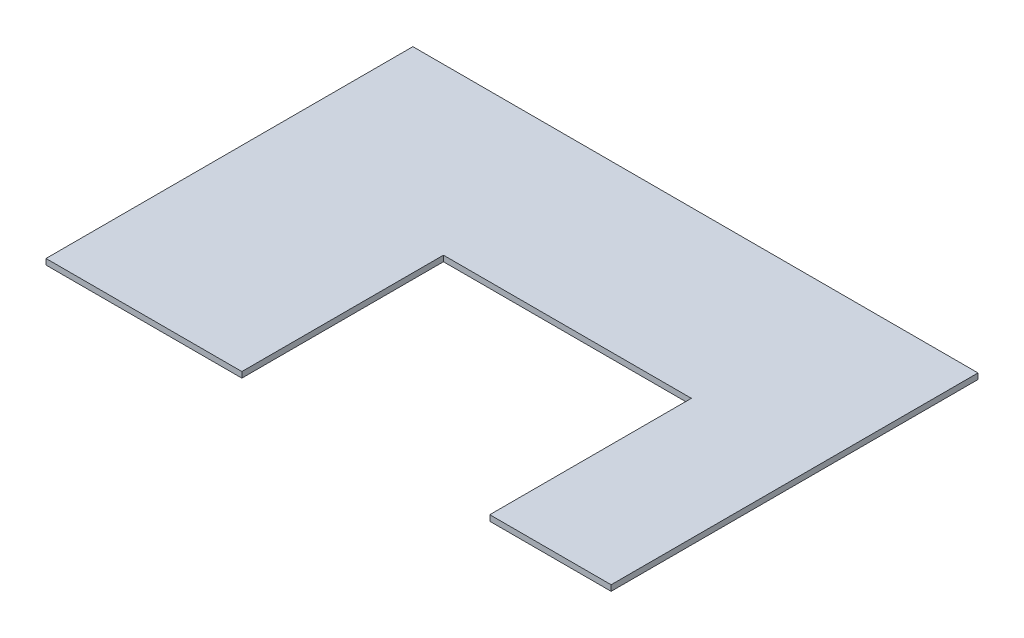
from build123d import *

# Parameters (mm, degrees)
BOSS_EXTRUDE1_DEPTH = 19.05


with BuildPart() as part:
    # Sketch1 → Boss-Extrude1 (new body)
    with BuildSketch(Plane(origin=(0, 0, 0), x_dir=(1, 0, 0), z_dir=(0, 1, 0))):
        Polygon((650.875, 0), (650.875, 669.925), (1474.7875, 669.925), (1474.7875, 0), (1878.0125, 0), (1878.0125, 1219.2), (0, 1219.2), (0, 0), align=None)
    extrude(amount=-BOSS_EXTRUDE1_DEPTH)


solid = part.part
